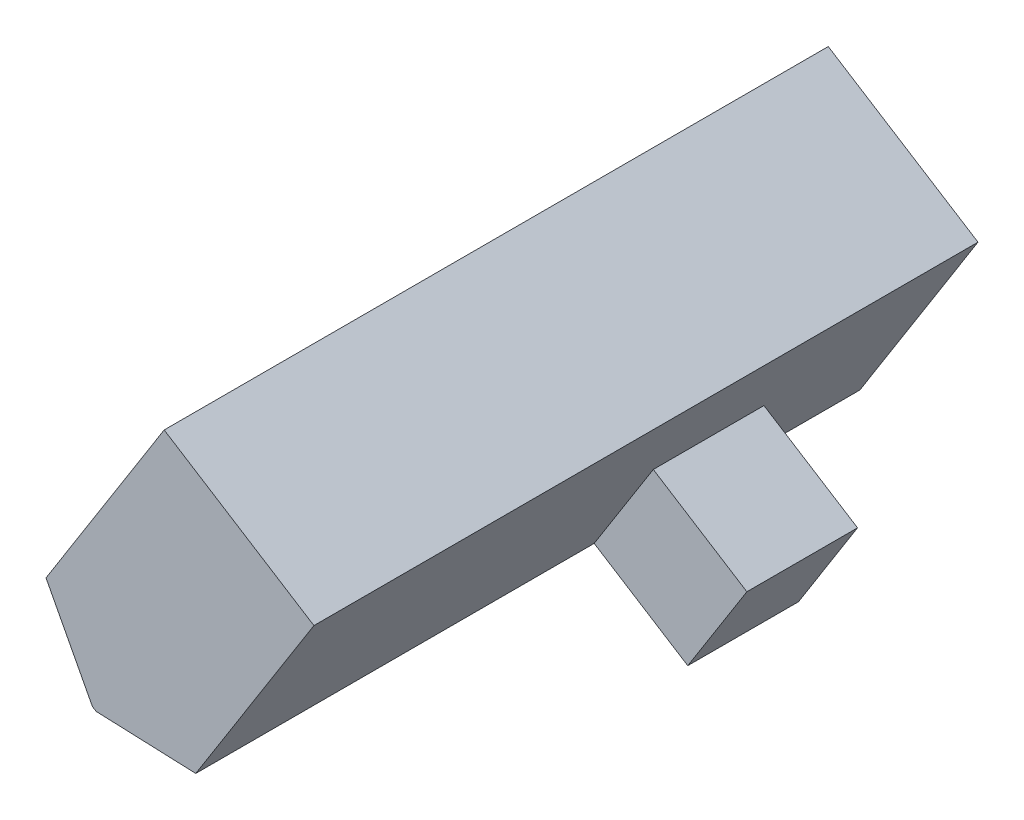
from build123d import *

# Parameters (mm, degrees)
BOSS_EXTRUDE2_DEPTH = 30
SKETCH3_W           = 8
SKETCH3_H           = 30
BOSS_EXTRUDE3_DEPTH = 10
BOSS_EXTRUDE4_DEPTH = 23
CUT_EXTRUDE1_DEPTH  = 18


with BuildPart() as part:
    # Sketch2 → Boss-Extrude2 (new body)
    with BuildSketch(Plane.XY):
        Polygon((16.826264571, 24.026772498), (14.730988717, 28.012523819), (21.495359976, 23.741308364), (16.995960151, 23.919621906), align=None)
    extrude(amount=BOSS_EXTRUDE2_DEPTH)

    # Sketch3 → Boss-Extrude3 (add)
    with BuildSketch(Plane(origin=(16.845028917, 26.677659006, 0), x_dir=(0.845546407, -0.533901932, 0), z_dir=(0.533901932, 0.845546407, 0))):
        with Locations((1.499794001, -15)):
            Rectangle(SKETCH3_W, SKETCH3_H)
    extrude(amount=BOSS_EXTRUDE3_DEPTH)

    # Sketch5 → Boss-Extrude4 (add)
    with BuildSketch(Plane.XY.offset(30)):
        Polygon((24.164869635, 27.969040401), (28.392601672, 25.299530741), (25.723092013, 21.071798704), (21.495359976, 23.741308364), align=None)
    extrude(amount=-BOSS_EXTRUDE4_DEPTH)

    # Sketch6 → Cut-Extrude1 (cut)
    with BuildSketch(Plane.XY.offset(30)):
        Polygon((21.495359976, 23.741308364), (24.164869635, 27.969040401), (28.392601672, 25.299530741), (25.723092013, 21.071798704), align=None)
    extrude(amount=-CUT_EXTRUDE1_DEPTH, mode=Mode.SUBTRACT)


solid = part.part
